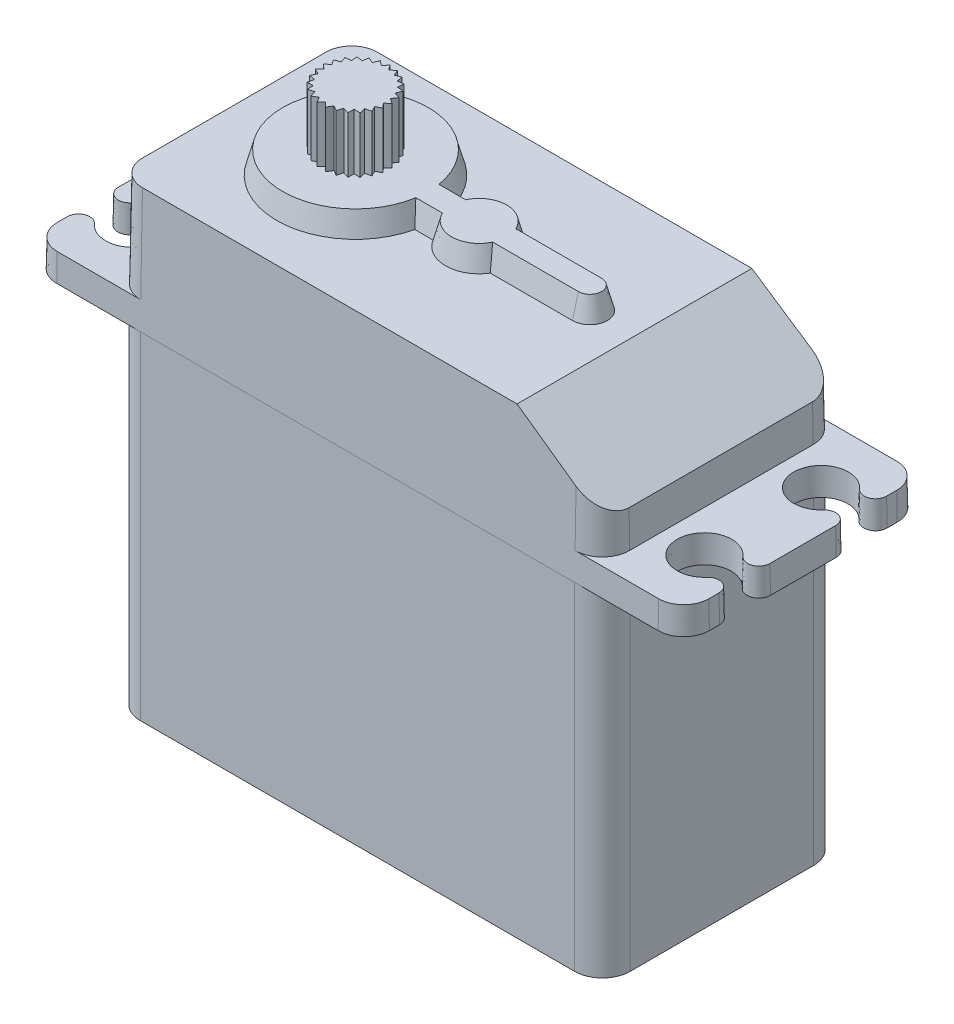
from build123d import *

# Parameters (mm, degrees)
BOSS_EXTRUDE1_DEPTH     = 28.88
BOSS_EXTRUDE2_DEPTH     = 10.6
BOSS_EXTRUDE2_TAPER     = 1
BOSS_EXTRUDE3_DEPTH     = 2.35
BOSS_EXTRUDE3_TAPER     = 1
CUT_EXTRUDE1_DEPTH      = 42.493584235
CUT_EXTRUDE1_DEPTH_BACK = 42.493584235
BOSS_EXTRUDE4_DEPTH     = 1.9
BOSS_EXTRUDE4_DRAFT     = 15
SKETCH5_R               = 2.95
BOSS_EXTRUDE5_DEPTH     = 4.8
SKETCH6_OUTSIDE_W       = 73.028
SKETCH6_OUTSIDE_H       = 37.578
CUT_EXTRUDE2_DEPTH      = 4.8


with BuildPart() as part:
    # Sketch1 → Boss-Extrude1 (new body)
    with BuildSketch(Plane(origin=(0, 0, 0), x_dir=(1, 0, 0), z_dir=(0, 1, 0))):
        with BuildLine():
            Line((-18.61875, -10.25), (18.61875, -10.25))
            ThreePointArc((18.61875, -10.25), (20.302548023, -9.552548023), (21, -7.86875))
            Line((21, -7.86875), (21, 7.86875))
            ThreePointArc((21, 7.86875), (20.302548023, 9.552548023), (18.61875, 10.25))
            Line((18.61875, 10.25), (-18.61875, 10.25))
            ThreePointArc((-18.61875, 10.25), (-20.302548023, 9.552548023), (-21, 7.86875))
            Line((-21, 7.86875), (-21, -7.86875))
            ThreePointArc((-21, -7.86875), (-20.302548023, -9.552548023), (-18.61875, -10.25))
        make_face()
    extrude(amount=-BOSS_EXTRUDE1_DEPTH)

    # Sketch1_2 → Boss-Extrude2 (add)
    with BuildSketch(Plane(origin=(0, 0, 0), x_dir=(1, 0, 0), z_dir=(0, 1, 0))):
        with BuildLine():
            Line((-18.61875, -10.25), (18.61875, -10.25))
            ThreePointArc((18.61875, -10.25), (20.302548023, -9.552548023), (21, -7.86875))
            Line((21, -7.86875), (21, 7.86875))
            ThreePointArc((21, 7.86875), (20.302548023, 9.552548023), (18.61875, 10.25))
            Line((18.61875, 10.25), (-18.61875, 10.25))
            ThreePointArc((-18.61875, 10.25), (-20.302548023, 9.552548023), (-21, 7.86875))
            Line((-21, 7.86875), (-21, -7.86875))
            ThreePointArc((-21, -7.86875), (-20.302548023, -9.552548023), (-18.61875, -10.25))
        make_face()
    extrude(amount=BOSS_EXTRUDE2_DEPTH, taper=BOSS_EXTRUDE2_TAPER)

    # Sketch2 → Boss-Extrude3 (add)
    with BuildSketch(Plane(origin=(0, 0, 0), x_dir=(1, 0, 0), z_dir=(0, 1, 0))):
        with BuildLine():
            ThreePointArc((-25.778773688, 10.25), (-27.331740206, 9.606740206), (-27.975, 8.053773688))
            Line((-27.975, 8.053773688), (-27.975, 7.182744832))
            ThreePointArc((-27.975, 7.182744832), (-27.328553391, 6.247330485), (-26.225, 6.521307004))
            ThreePointArc((-26.225, 6.521307004), (-22.2, 5), (-26.225, 3.478692996))
            ThreePointArc((-26.225, 3.478692996), (-27.328553391, 3.752669515), (-27.975, 2.817255168))
            Line((-27.975, 2.817255168), (-27.975, -2.817255168))
            ThreePointArc((-27.975, -2.817255168), (-27.328553391, -3.752669515), (-26.225, -3.478692996))
            ThreePointArc((-26.225, -3.478692996), (-22.2, -5), (-26.225, -6.521307004))
            ThreePointArc((-26.225, -6.521307004), (-27.328553391, -6.247330485), (-27.975, -7.182744832))
            Line((-27.975, -7.182744832), (-27.975, -8.053773688))
            ThreePointArc((-27.975, -8.053773688), (-27.331740206, -9.606740206), (-25.778773688, -10.25))
            Line((-25.778773688, -10.25), (25.778773688, -10.25))
            ThreePointArc((25.778773688, -10.25), (27.331740206, -9.606740206), (27.975, -8.053773688))
            Line((27.975, -8.053773688), (27.975, -7.182744832))
            ThreePointArc((27.975, -7.182744832), (27.328553391, -6.247330485), (26.225, -6.521307004))
            ThreePointArc((26.225, -6.521307004), (22.2, -5), (26.225, -3.478692996))
            ThreePointArc((26.225, -3.478692996), (27.328553391, -3.752669515), (27.975, -2.817255168))
            Line((27.975, -2.817255168), (27.975, 2.817255168))
            ThreePointArc((27.975, 2.817255168), (27.328553391, 3.752669515), (26.225, 3.478692996))
            ThreePointArc((26.225, 3.478692996), (22.2, 5), (26.225, 6.521307004))
            ThreePointArc((26.225, 6.521307004), (27.328553391, 6.247330485), (27.975, 7.182744832))
            Line((27.975, 7.182744832), (27.975, 8.053773688))
            ThreePointArc((27.975, 8.053773688), (27.331740206, 9.606740206), (25.778773688, 10.25))
            Line((25.778773688, 10.25), (-25.778773688, 10.25))
        make_face()
    extrude(amount=BOSS_EXTRUDE3_DEPTH, taper=BOSS_EXTRUDE3_TAPER)

    # Sketch3 → Cut-Extrude1 (cut, two sides: drawn at the far end of the back side and taken through both)
    with BuildSketch(Plane.XY.offset(-CUT_EXTRUDE1_DEPTH_BACK)):
        Polygon((20.903997143, 5.5), (13.5, 10.6), (20.814976312, 10.6), align=None)
    extrude(amount=CUT_EXTRUDE1_DEPTH + CUT_EXTRUDE1_DEPTH_BACK, mode=Mode.SUBTRACT)


with BuildPart() as boss_extrude4_tool:
    # Sketch4 → Boss-Extrude4 (with draft: the straight prism first)
    with BuildSketch(Plane(origin=(0, 10.6, 0), x_dir=(1, 0, 0), z_dir=(0, 1, 0))):
        with BuildLine():
            Line((-3.833753021, -1.5), (-2.267653421, -1.5))
            ThreePointArc((-2.267653421, -1.5), (0.185023688, -2.875), (2.637700797, -1.5))
            Line((2.637700797, -1.5), (9.685023688, -1.5))
            ThreePointArc((9.685023688, -1.5), (11.185023688, 0), (9.685023688, 1.5))
            Line((9.685023688, 1.5), (2.637700797, 1.5))
            ThreePointArc((2.637700797, 1.5), (0.185023688, 2.875), (-2.267653421, 1.5))
            Line((-2.267653421, 1.5), (-3.833753021, 1.5))
            ThreePointArc((-3.833753021, 1.5), (-17.164976312, 0), (-3.833753021, -1.5))
        make_face()
    extrude(amount=BOSS_EXTRUDE4_DEPTH)
    # Boss-Extrude4: the draft: its side faces are tilted about the plane it starts from
    boss_extrude4_sides = [boss_extrude4_tool.faces().sort_by_distance(p)[0] for p in [
        (-3.050703221, 11.55, 1.5),
        (0.185023688, 11.55, 2.875),
        (6.161362243, 11.55, 1.5),
        (11.185023688, 11.55, 0),
        (6.161362243, 11.55, -1.5),
        (0.185023688, 11.55, -2.875),
        (-3.050703221, 11.55, -1.5),
        (-17.164976312, 11.55, 0),
    ]]
    draft(boss_extrude4_sides, Plane(origin=(0, 10.6, 0), x_dir=(1, 0, 0), z_dir=(0, 1, 0)), BOSS_EXTRUDE4_DRAFT)


with BuildPart() as part_1:
    add(part.part)

    # Boss-Extrude4: add boss_extrude4_tool
    add(boss_extrude4_tool.part)

    # Sketch5 → Boss-Extrude5 (add)
    with BuildSketch(Plane(origin=(0, 12.5, 0), x_dir=(1, 0, 0), z_dir=(0, 1, 0))):
        with Locations((-10.414976312, 0)):
            Circle(SKETCH5_R)
    extrude(amount=BOSS_EXTRUDE5_DEPTH)

    # Sketch6 outside → Cut-Extrude2 (cut)
    with BuildSketch(Plane(origin=(0, 12.5, 0), x_dir=(1, 0, 0), z_dir=(0, 1, 0))):
        Rectangle(SKETCH6_OUTSIDE_W, SKETCH6_OUTSIDE_H)
        Polygon((-9.183129599, -2.240720851), (-8.681009817, -2.386600133), (-8.664585713, -1.863976666), (-8.141962246, -1.88040077), (-8.256025306, -1.370111971), (-7.745736507, -1.25604891), (-7.983119731, -0.790158102), (-7.517228922, -0.552774878), (-7.863016648, -0.160555693), (-7.470797463, 0.185232033), (-7.903262576, 0.47913502), (-7.609359589, 0.911600133), (-8.101328716, 1.088719918), (-7.924208932, 1.580689045), (-8.444769843, 1.629896539), (-8.395562349, 2.150457451), (-8.912006289, 2.068660767), (-8.993802973, 2.585104706), (-9.473679868, 2.37744343), (-9.681341145, 2.857320325), (-10.094498566, 2.536842579), (-10.414976312, 2.95), (-10.735454058, 2.536842579), (-11.148611479, 2.857320325), (-11.356272755, 2.37744343), (-11.83614965, 2.585104706), (-11.917946335, 2.068660767), (-12.434390274, 2.150457451), (-12.38518278, 1.629896539), (-12.905743692, 1.580689045), (-12.728623908, 1.088719918), (-13.220593035, 0.911600133), (-12.926690047, 0.47913502), (-13.359155161, 0.185232033), (-12.966935976, -0.160555693), (-13.312723701, -0.552774878), (-12.846832893, -0.790158102), (-13.084216117, -1.25604891), (-12.573927317, -1.370111971), (-12.687990378, -1.88040077), (-12.16536691, -1.863976666), (-12.148942806, -2.386600133), (-11.646823024, -2.240720851), (-11.500943742, -2.742840633), (-11.050877679, -2.476672305), (-10.784709351, -2.926738369), (-10.414976312, -2.55700533), (-10.045243273, -2.926738369), (-9.779074945, -2.476672305), (-9.329008881, -2.742840633), align=None, mode=Mode.SUBTRACT)
    extrude(amount=CUT_EXTRUDE2_DEPTH, mode=Mode.SUBTRACT)


solid = part_1.part
